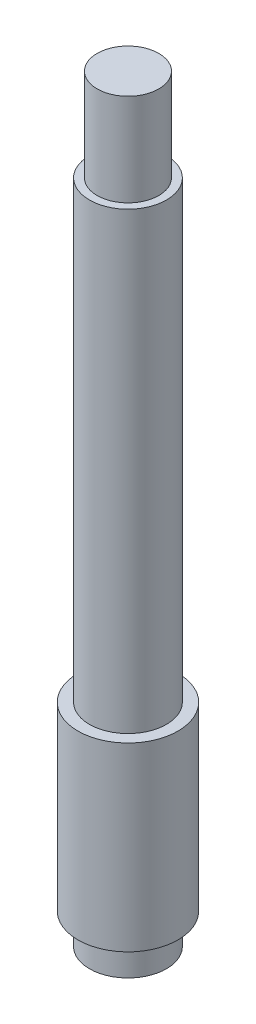
from build123d import *


with BuildPart() as part:
    # 草圖1 → 旋轉1 (revolve)
    with BuildSketch(Plane.XY):
        Polygon((0, 0), (5, 0), (5, 4), (6.5, 4), (6.5, 27.5), (5, 27.5), (5, 86.5), (4, 86.5), (4, 98.5), (0, 98.5), align=None)
    revolve(axis=Axis((0, 463.328385711, 0), (0, -1, 0)))


solid = part.part
